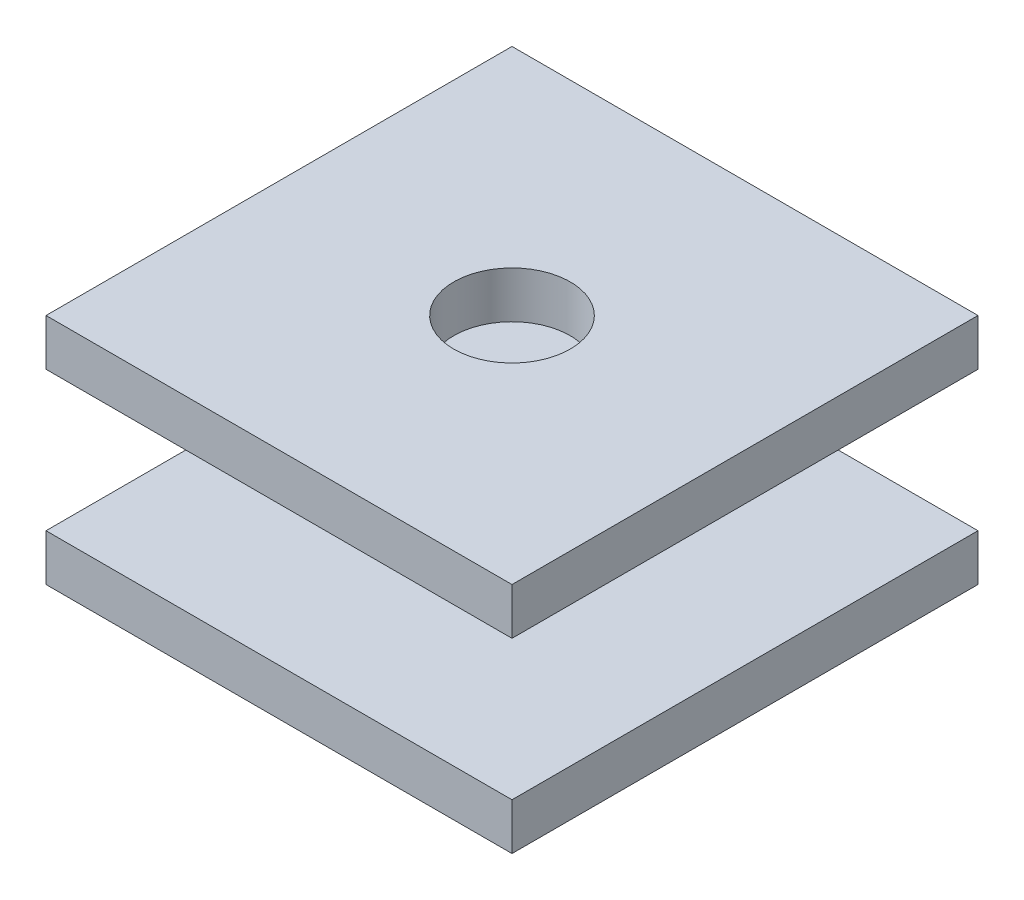
from build123d import *

# Parameters (mm, degrees)
SKETCH1_W           = 25.4
SKETCH1_H           = 25.4
BOSS_EXTRUDE1_DEPTH = 2.54
SKETCH2_R           = 2.54
BOSS_EXTRUDE2_DEPTH = 2.54
SKETCH3_R           = 3.81
BOSS_EXTRUDE3_DEPTH = 7.62
SKETCH4_W           = 25.4
SKETCH4_H           = 25.4
BOSS_EXTRUDE4_DEPTH = 2.54
SKETCH5_R           = 3.175
CUT_EXTRUDE2_DEPTH  = 2.54


with BuildPart() as part:
    # Sketch1 → Boss-Extrude1 (new body)
    with BuildSketch(Plane(origin=(0, 0, 0), x_dir=(1, 0, 0), z_dir=(0, 1, 0))):
        with Locations((12.7, 12.7)):
            Rectangle(SKETCH1_W, SKETCH1_H)
    extrude(amount=BOSS_EXTRUDE1_DEPTH)

    # Sketch2 → Boss-Extrude2 (add)
    with BuildSketch(Plane.XZ):
        with Locations((12.7, -12.7)):
            Circle(SKETCH2_R)
    extrude(amount=BOSS_EXTRUDE2_DEPTH)

    # Sketch3 → Boss-Extrude3 (add)
    with BuildSketch(Plane(origin=(0, 2.54, 0), x_dir=(1, 0, 0), z_dir=(0, 1, 0))):
        with Locations((12.7, 12.7)):
            Circle(SKETCH3_R)
    extrude(amount=BOSS_EXTRUDE3_DEPTH)

    # Sketch4 → Boss-Extrude4 (add)
    with BuildSketch(Plane(origin=(0, 10.16, 0), x_dir=(1, 0, 0), z_dir=(0, 1, 0))):
        with Locations((12.7, 12.7)):
            Rectangle(SKETCH4_W, SKETCH4_H)
    extrude(amount=BOSS_EXTRUDE4_DEPTH)

    # Sketch5 → Cut-Extrude2 (cut)
    with BuildSketch(Plane(origin=(0, 12.7, 0), x_dir=(1, 0, 0), z_dir=(0, 1, 0))):
        with Locations((12.7, 12.7)):
            Circle(SKETCH5_R)
    extrude(amount=-CUT_EXTRUDE2_DEPTH, mode=Mode.SUBTRACT)


solid = part.part
